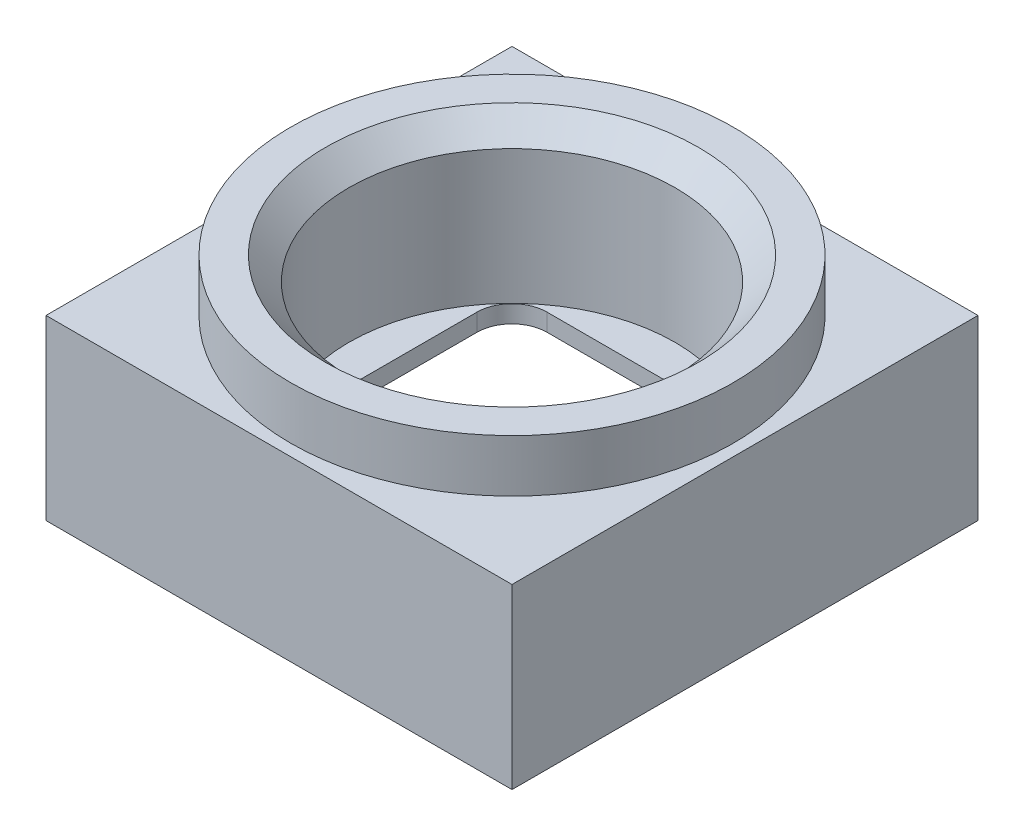
from build123d import *

# Parameters (mm, degrees)
SKIZZE2_W                       = 8
SKIZZE2_H                       = 8
SKIZZE2_W_2                     = 7.4
SKIZZE2_H_2                     = 7.4
AUFSATZ_LINEAR_AUSTRAGEN1_DEPTH = 0.6
SKIZZE5_W                       = 8
SKIZZE5_H                       = 8
AUFSATZ_LINEAR_AUSTRAGEN3_DEPTH = 0.35
SKIZZE4_W                       = 8
SKIZZE4_H                       = 8
AUFSATZ_LINEAR_AUSTRAGEN2_DEPTH = 0.3
SKIZZE7_W                       = 8
SKIZZE7_H                       = 8
SKIZZE7_R                       = 2.8
AUFSATZ_LINEAR_AUSTRAGEN4_DEPTH = 1.8
SKIZZE8_R                       = 3.8
SKIZZE8_R_2                     = 2.8
AUFSATZ_LINEAR_AUSTRAGEN5_DEPTH = 0.9
FASE1_SIZE                      = 0.4


with BuildPart() as part:
    # Skizze2 → Aufsatz-Linear austragen1 (new body)
    with BuildSketch(Plane(origin=(0, 0, 0), x_dir=(1, 0, 0), z_dir=(0, 1, 0))):
        Rectangle(SKIZZE2_W, SKIZZE2_H)
        Rectangle(SKIZZE2_W_2, SKIZZE2_H_2, mode=Mode.SUBTRACT)
    extrude(amount=AUFSATZ_LINEAR_AUSTRAGEN1_DEPTH)

    # Skizze5 → Aufsatz-Linear austragen3 (add)
    with BuildSketch(Plane(origin=(0, 0.6, 0), x_dir=(1, 0, 0), z_dir=(0, 1, 0))):
        Rectangle(SKIZZE5_W, SKIZZE5_H)
        with BuildLine():
            Line((-2.764589803, 3.2), (2.764589803, 3.2))
            ThreePointArc((2.764589803, 3.2), (3.347487373, 3.347487373), (3.2, 2.764589803))
            Line((3.2, 2.764589803), (3.2, -2.764589803))
            ThreePointArc((3.2, -2.764589803), (3.347487373, -3.347487373), (2.764589803, -3.2))
            Line((2.764589803, -3.2), (-2.764589803, -3.2))
            ThreePointArc((-2.764589803, -3.2), (-3.347487373, -3.347487373), (-3.2, -2.764589803))
            Line((-3.2, -2.764589803), (-3.2, 2.764589803))
            ThreePointArc((-3.2, 2.764589803), (-3.347487373, 3.347487373), (-2.764589803, 3.2))
        make_face(mode=Mode.SUBTRACT)
    extrude(amount=AUFSATZ_LINEAR_AUSTRAGEN3_DEPTH)

    # Skizze4 → Aufsatz-Linear austragen2 (add)
    with BuildSketch(Plane(origin=(0, 0.95, 0), x_dir=(1, 0, 0), z_dir=(0, 1, 0))):
        Rectangle(SKIZZE4_W, SKIZZE4_H)
        with BuildLine():
            Line((-1.55, 2.15), (1.55, 2.15))
            ThreePointArc((1.55, 2.15), (1.974264069, 1.974264069), (2.15, 1.55))
            Line((2.15, 1.55), (2.15, -1.55))
            ThreePointArc((2.15, -1.55), (1.974264069, -1.974264069), (1.55, -2.15))
            Line((1.55, -2.15), (-1.55, -2.15))
            ThreePointArc((-1.55, -2.15), (-1.974264069, -1.974264069), (-2.15, -1.55))
            Line((-2.15, -1.55), (-2.15, 1.55))
            ThreePointArc((-2.15, 1.55), (-1.974264069, 1.974264069), (-1.55, 2.15))
        make_face(mode=Mode.SUBTRACT)
    extrude(amount=AUFSATZ_LINEAR_AUSTRAGEN2_DEPTH)

    # Skizze7 → Aufsatz-Linear austragen4 (add)
    with BuildSketch(Plane(origin=(0, 1.25, 0), x_dir=(1, 0, 0), z_dir=(0, 1, 0))):
        Rectangle(SKIZZE7_W, SKIZZE7_H)
        with Locations(Location((0, 0, 0), (0, 0, 270))):  # turned: the seam where the file's is
            Circle(SKIZZE7_R, mode=Mode.SUBTRACT)
    extrude(amount=AUFSATZ_LINEAR_AUSTRAGEN4_DEPTH)

    # Skizze8 → Aufsatz-Linear austragen5 (add)
    with BuildSketch(Plane(origin=(0, 3.05, 0), x_dir=(1, 0, 0), z_dir=(0, 1, 0))):
        with Locations(Location((0, 0, 0), (0, 0, 270))):  # turned: the seam where the file's is
            Circle(SKIZZE8_R)
        with Locations(Location((0, 0, 0), (0, 0, 270))):  # turned: the seam where the file's is
            Circle(SKIZZE8_R_2, mode=Mode.SUBTRACT)
    extrude(amount=AUFSATZ_LINEAR_AUSTRAGEN5_DEPTH)

    # Fase1
    fase1_edges = [part.edges().sort_by_distance(p)[0] for p in [
        (0, 3.95, -2.8),
    ]]
    chamfer(fase1_edges, length=FASE1_SIZE)


solid = part.part
